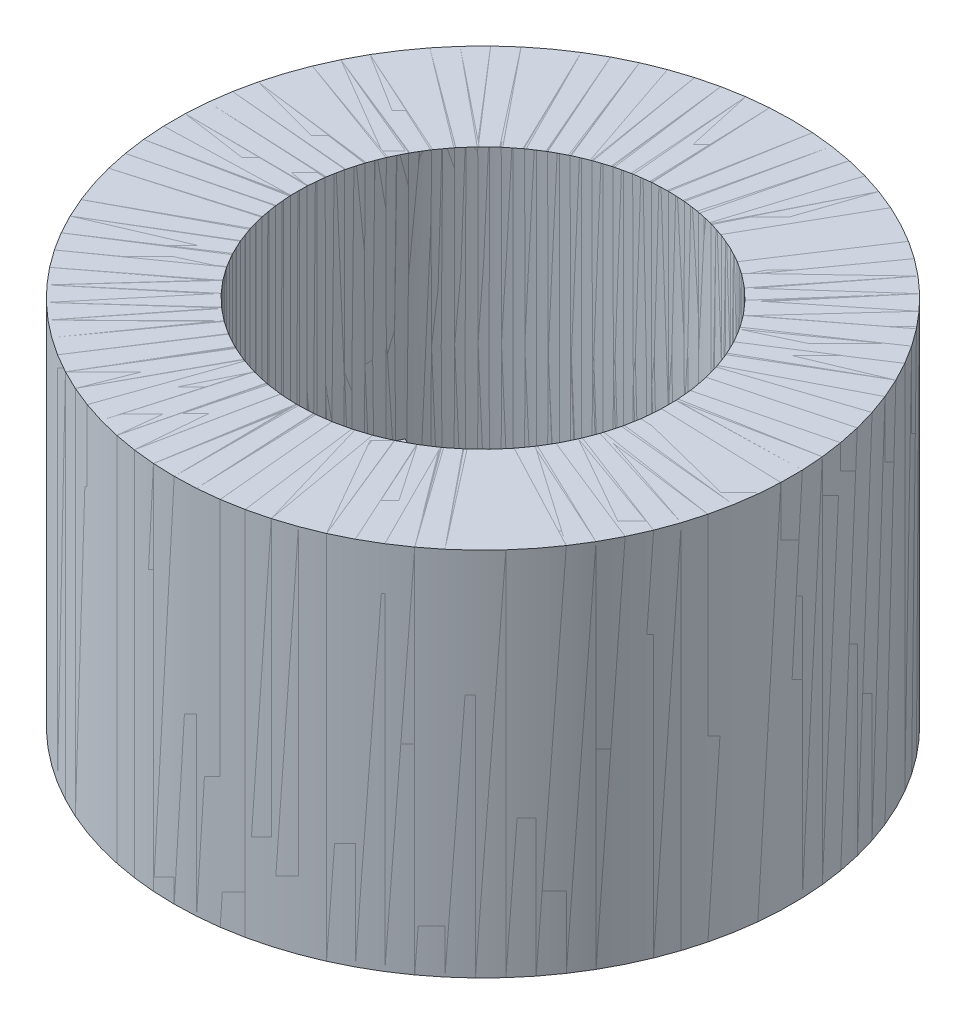
from build123d import *

# Parameters (mm, degrees)
SKETCH1_R           = 25
BOSS_EXTRUDE1_DEPTH = 30
BOSS_EXTRUDE3_DEPTH = 10
SKETCH1_3_R         = 3
BOSS_EXTRUDE2_DEPTH = 10
CIRPATTERN7_COUNT   = 5


with BuildPart() as part:
    # Sketch1 → Boss-Extrude1 (new body)
    with BuildSketch(Plane(origin=(0, 0, 0), x_dir=(1, 0, 0), z_dir=(0, 1, 0))):
        Circle(SKETCH1_R)
        with BuildLine():
            ThreePointArc((15, 0), (-9.670202954, -11.466785724), (-2.531623311, 14.784819357))
            ThreePointArc((-2.531623311, 14.784819357), (0, 15), (2.531623311, 14.784819357))
            ThreePointArc((2.531623311, 14.784819357), (11.466785724, 9.670202954), (15, 0))
        make_face(mode=Mode.SUBTRACT)
    extrude(amount=BOSS_EXTRUDE1_DEPTH)

    # Sketch1_4 → Boss-Extrude3 (add)
    with BuildSketch(Plane(origin=(0, 0, 0), x_dir=(1, 0, 0), z_dir=(0, 1, 0))):
        with BuildLine():
            ThreePointArc((2.531623311, 14.784819357), (0, 15), (-2.531623311, 14.784819357))
            Line((-2.531623311, 14.784819357), (-1.5, 9.284819357))
            Line((-1.5, 9.284819357), (-1.451035397, 4.784819357))
            ThreePointArc((-1.451035397, 4.784819357), (0, 5), (1.451035397, 4.784819357))
            Line((1.451035397, 4.784819357), (1.5, 9.284819357))
            Line((1.5, 9.284819357), (2.531623311, 14.784819357))
        make_face()
    extrude(amount=BOSS_EXTRUDE3_DEPTH)


with BuildPart() as body_2:
    # Sketch1_3 → Boss-Extrude2 (new body)
    with BuildSketch(Plane(origin=(0, 0, 0), x_dir=(1, 0, 0), z_dir=(0, 1, 0))):
        with BuildLine():
            ThreePointArc((1.451035397, 4.784819357), (0, 5), (-1.451035397, 4.784819357))
            ThreePointArc((-1.451035397, 4.784819357), (-2.978659347, -4.015916893), (5, 0))
            ThreePointArc((5, 0), (4.015916893, 2.978659347), (1.451035397, 4.784819357))
        make_face()
        Circle(SKETCH1_3_R, mode=Mode.SUBTRACT)
    extrude(amount=BOSS_EXTRUDE2_DEPTH)


with BuildPart() as cirpattern7_1:
    # CirPattern7: pattern copy
    add(part.part.rotate(Axis((0, 0, 0), (0, 1, 0)), 1 * 360 / CIRPATTERN7_COUNT))


with BuildPart() as cirpattern7_2:
    # CirPattern7: pattern copy
    add(part.part.rotate(Axis((0, 0, 0), (0, 1, 0)), 2 * 360 / CIRPATTERN7_COUNT))


with BuildPart() as cirpattern7_3:
    # CirPattern7: pattern copy
    add(part.part.rotate(Axis((0, 0, 0), (0, 1, 0)), 3 * 360 / CIRPATTERN7_COUNT))


with BuildPart() as cirpattern7_4:
    # CirPattern7: pattern copy
    add(part.part.rotate(Axis((0, 0, 0), (0, 1, 0)), 4 * 360 / CIRPATTERN7_COUNT))


solid = Compound([part.part, body_2.part, cirpattern7_1.part, cirpattern7_2.part, cirpattern7_3.part, cirpattern7_4.part])
